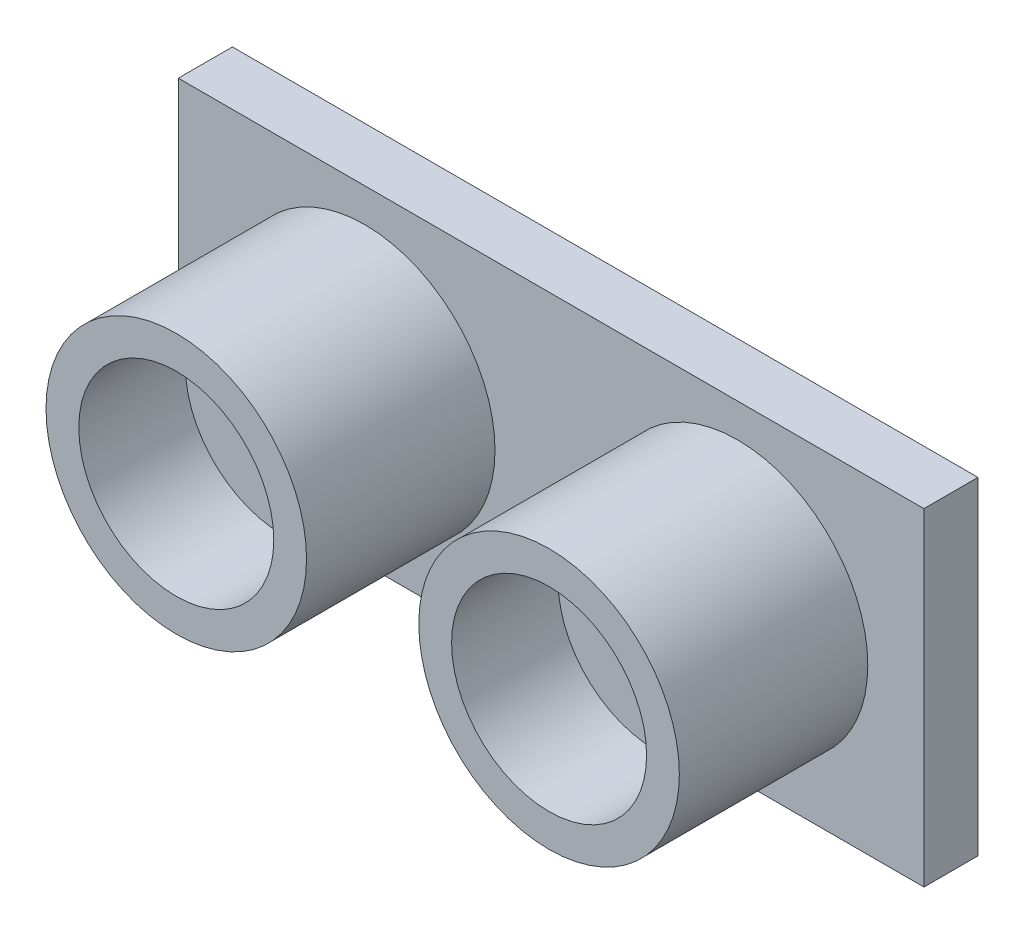
from build123d import *

# Parameters (mm, degrees)
CROQUIS1_W              = 45.5
CROQUIS1_H              = 20
SALIENTE_EXTRUIR1_DEPTH = 3.3
CROQUIS2_R              = 7.95
SALIENTE_EXTRUIR2_DEPTH = 11.5
CROQUIS3_R              = 5.95
CORTAR_EXTRUIR1_DEPTH   = 6.5
CROQUIS4_W              = 10
CROQUIS4_H              = 2.5
SALIENTE_EXTRUIR3_DEPTH = 2.5
CROQUIS5_W              = 2.4
CROQUIS5_H              = 2.4
SALIENTE_EXTRUIR4_DEPTH = 2
CROQUIS6_W              = 2.4
CROQUIS6_H              = 1.5
SALIENTE_EXTRUIR5_DEPTH = 5.3


with BuildPart() as part:
    # Croquis1 → Saliente-Extruir1 (new body)
    with BuildSketch(Plane.XY):
        with Locations((22.75, 10)):
            Rectangle(CROQUIS1_W, CROQUIS1_H)
    extrude(amount=SALIENTE_EXTRUIR1_DEPTH)

    # Croquis2 → Saliente-Extruir2 (add)
    with BuildSketch(Plane.XY.offset(3.3)):
        with Locations((34.125, 10)):
            Circle(CROQUIS2_R)
        with Locations((11.375, 10)):
            Circle(CROQUIS2_R)
    extrude(amount=SALIENTE_EXTRUIR2_DEPTH)

    # Croquis3 → Cortar-Extruir1 (cut)
    with BuildSketch(Plane.XY.offset(14.8)):
        with Locations((34.125, 10)):
            Circle(CROQUIS3_R)
        with Locations((11.375, 10)):
            Circle(CROQUIS3_R)
    extrude(amount=-CORTAR_EXTRUIR1_DEPTH, mode=Mode.SUBTRACT)

    # Croquis4 → Saliente-Extruir3 (add)
    with BuildSketch(Plane(origin=(0, 0, 0), x_dir=(-1, 0, 0), z_dir=(0, 0, -1))):
        with Locations((-22.5, 1.25)):
            Rectangle(CROQUIS4_W, CROQUIS4_H)
    extrude(amount=SALIENTE_EXTRUIR3_DEPTH)

    # Croquis5 → Saliente-Extruir4 (add)
    with BuildSketch(Plane(origin=(0, 0, -2.5), x_dir=(-1, 0, 0), z_dir=(0, 0, -1))):
        with Locations((-26.235, 1.25)):
            Rectangle(CROQUIS5_W, CROQUIS5_H)
        with Locations((-23.745, 1.25)):
            Rectangle(CROQUIS5_W, CROQUIS5_H)
        with Locations((-21.255, 1.25)):
            Rectangle(CROQUIS5_W, CROQUIS5_H)
        with Locations((-18.765, 1.25)):
            Rectangle(CROQUIS5_W, CROQUIS5_H)
    extrude(amount=SALIENTE_EXTRUIR4_DEPTH)

    # Croquis6 → Saliente-Extruir5 (add)
    with BuildSketch(Plane.XZ.offset(-0.05)):
        with Locations((18.765, -3.75)):
            Rectangle(CROQUIS6_W, CROQUIS6_H)
        with Locations((21.255, -3.75)):
            Rectangle(CROQUIS6_W, CROQUIS6_H)
        with Locations((23.745, -3.75)):
            Rectangle(CROQUIS6_W, CROQUIS6_H)
        with Locations((26.235, -3.75)):
            Rectangle(CROQUIS6_W, CROQUIS6_H)
    extrude(amount=SALIENTE_EXTRUIR5_DEPTH)


solid = part.part
